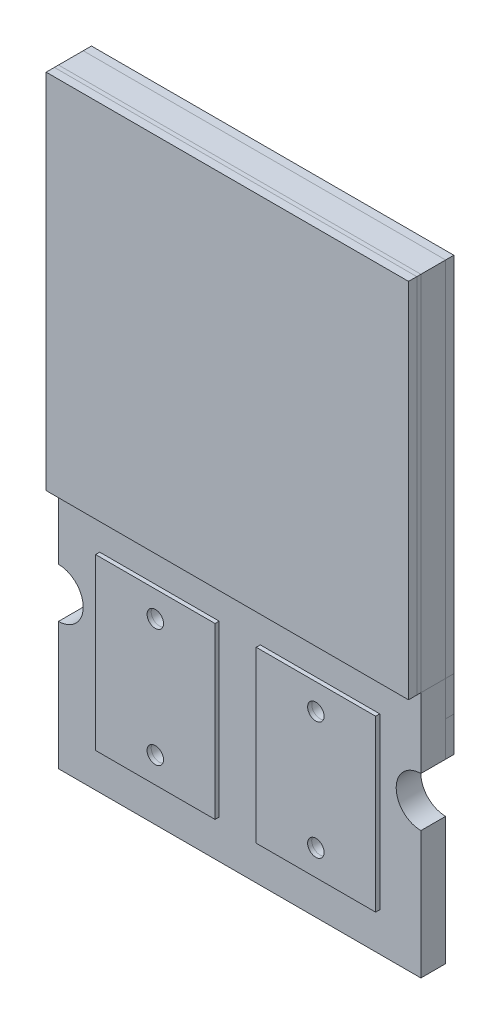
from build123d import *

# Parameters (mm, degrees)
BOSS_EXTRUDE1_DEPTH   = 0.3
BOSS_EXTRUDE2_DEPTH   = 0.05
SKETCH2_W             = 1.449629897
SKETCH2_H             = 1.2
BOSS_EXTRUDE2_2_DEPTH = 0.05
SKETCH2_W_2           = 1.45
SKETCH2_H_2           = 1.199587339
BOSS_EXTRUDE2_3_DEPTH = 0.05
BOSS_EXTRUDE3_DEPTH   = 0.05
SKETCH4_W             = 1.45037802
SKETCH4_H             = 2.060210665
BOSS_EXTRUDE4_DEPTH   = 0.05
SKETCH4_W_2           = 1.449629897
BOSS_EXTRUDE4_2_DEPTH = 0.05
SKETCH4_W_3           = 4.4
SKETCH4_H_2           = 4.4
BOSS_EXTRUDE4_3_DEPTH = 0.05
SKETCH6_W             = 4.399859889
SKETCH6_H             = 4.4
BOSS_EXTRUDE5_DEPTH   = 0.1
SKETCH7_R             = 0.1
CUT_EXTRUDE1_DEPTH    = 0.4


with BuildPart() as part:
    # Model → Boss-Extrude1 (new body)
    with BuildSketch(Plane.XY):
        Polygon((0.000140111, 4.4), (0, 0), (4.400140111, 0), (4.400140111, 4.4), align=None)
        with BuildLine():
            ThreePointArc((4.4, -0.85), (4.1, -1.15), (4.4, -1.45))
            Line((4.4, -1.45), (4.4, -3))
            Line((4.4, -3), (0, -3))
            Line((0, -3), (0, -1.45))
            ThreePointArc((0, -1.45), (0.3, -1.15), (0, -0.85))
            Line((0, -0.85), (0, 0))
            Line((0, 0), (4.400140111, 0))
            Line((4.400140111, 0), (4.4, -0.85))
        make_face()
    extrude(amount=BOSS_EXTRUDE1_DEPTH)


with BuildPart() as body_2:
    # Sketch2 → Boss-Extrude2 (new body)
    with BuildSketch(Plane(origin=(0, 0, 0), x_dir=(-1, 0, 0), z_dir=(0, 0, -1))):
        with BuildLine():
            Line((-4.100667409, -1.13), (-0.299472702, -1.13))
            ThreePointArc((-0.299472702, -1.13), (-0.205079126, -0.930910977), (-0.000140111, -0.85))
            Line((-0.000140111, -0.85), (0, 0))
            Line((0, 0), (-0.000140111, 4.4))
            Line((-0.000140111, 4.4), (-4.4, 4.4))
            Line((-4.4, 4.4), (-4.4, 0))
            Line((-4.4, 0), (-4.400070055, -0.425))
            Line((-4.400070055, -0.425), (-4.4, -0.85))
            ThreePointArc((-4.4, -0.85), (-4.195060985, -0.930910977), (-4.100667409, -1.13))
        make_face()
    extrude(amount=BOSS_EXTRUDE2_DEPTH)

    # Sketch3 → Boss-Extrude3 (add)
    with BuildSketch(Plane(origin=(0, 0, -0.05), x_dir=(-1, 0, 0), z_dir=(0, 0, -1))):
        with BuildLine():
            Line((-0.000140111, -0.850000016), (0, 0))
            Line((0, 0), (-0.000140111, 4.4))
            Line((-0.000140111, 4.4), (-4.4, 4.4))
            Line((-4.4, 4.4), (-4.4, 0))
            Line((-4.4, 0), (-4.400070055, -0.425))
            Line((-4.400070055, -0.425), (-4.4, -0.85))
            ThreePointArc((-4.4, -0.85), (-4.195060985, -0.930910977), (-4.100667409, -1.13))
            Line((-4.100667409, -1.13), (-0.299472685, -1.130000001))
            ThreePointArc((-0.299472685, -1.130000001), (-0.205079115, -0.930910989), (-0.000140111, -0.850000016))
        make_face()
    extrude(amount=BOSS_EXTRUDE3_DEPTH)


with BuildPart() as body_3:
    # Sketch2 → Boss-Extrude2 2 (new body)
    with BuildSketch(Plane(origin=(0, 0, 0), x_dir=(-1, 0, 0), z_dir=(0, 0, -1))):
        with Locations((-3.174585387, -2.4)):
            Rectangle(SKETCH2_W, SKETCH2_H)
    extrude(amount=BOSS_EXTRUDE2_2_DEPTH)


with BuildPart() as body_4:
    # Sketch2 → Boss-Extrude2 3 (new body)
    with BuildSketch(Plane(origin=(0, 0, 0), x_dir=(-1, 0, 0), z_dir=(0, 0, -1))):
        with Locations((-1.224770438, -2.400206331)):
            Rectangle(SKETCH2_W_2, SKETCH2_H_2)
    extrude(amount=BOSS_EXTRUDE2_3_DEPTH)


with BuildPart() as body_5:
    # Sketch4 → Boss-Extrude4 (new body)
    with BuildSketch(Plane.XY.offset(0.3)):
        with Locations((3.175418572, -1.502294159)):
            Rectangle(SKETCH4_W, SKETCH4_H)
    extrude(amount=BOSS_EXTRUDE4_DEPTH)


with BuildPart() as body_6:
    # Sketch4 → Boss-Extrude4 2 (new body)
    with BuildSketch(Plane.XY.offset(0.3)):
        with Locations((1.225414614, -1.502294159)):
            Rectangle(SKETCH4_W_2, SKETCH4_H)
    extrude(amount=BOSS_EXTRUDE4_2_DEPTH)


with BuildPart() as body_7:
    # Sketch4 → Boss-Extrude4 3 (new body)
    with BuildSketch(Plane.XY.offset(0.3)):
        with Locations((2.2, 2.2)):
            Rectangle(SKETCH4_W_3, SKETCH4_H_2)
    extrude(amount=BOSS_EXTRUDE4_3_DEPTH)


with BuildPart() as body_8:
    # Sketch6 → Boss-Extrude5 (new body)
    with BuildSketch(Plane.XY.offset(0.35)):
        with Locations((2.200070056, 2.2)):
            Rectangle(SKETCH6_W, SKETCH6_H)
    extrude(amount=BOSS_EXTRUDE5_DEPTH)


with BuildPart() as cut_extrude1_tool:
    # Sketch7 → Cut-Extrude1 (new body)
    with BuildSketch(Plane.XY.offset(0.35)):
        with Locations((1.225414614, -0.786125011)):
            Circle(SKETCH7_R)
        with Locations((1.225414614, -2.218463306)):
            Circle(SKETCH7_R)
        with Locations((3.174621886, -2.218508824)):
            Circle(SKETCH7_R)
        with Locations((3.174688781, -0.78617053)):
            Circle(SKETCH7_R)
    extrude(amount=-CUT_EXTRUDE1_DEPTH)


with BuildPart() as part_1:
    add(part.part)

    # Cut-Extrude1: cut by cut_extrude1_tool
    add(cut_extrude1_tool.part, mode=Mode.SUBTRACT)


with BuildPart() as body_2_1:
    add(body_2.part)

    # Cut-Extrude1: cut by cut_extrude1_tool
    add(cut_extrude1_tool.part, mode=Mode.SUBTRACT)


with BuildPart() as body_3_1:
    add(body_3.part)

    # Cut-Extrude1: cut by cut_extrude1_tool
    add(cut_extrude1_tool.part, mode=Mode.SUBTRACT)


with BuildPart() as body_4_1:
    add(body_4.part)

    # Cut-Extrude1: cut by cut_extrude1_tool
    add(cut_extrude1_tool.part, mode=Mode.SUBTRACT)


with BuildPart() as body_5_1:
    add(body_5.part)

    # Cut-Extrude1: cut by cut_extrude1_tool
    add(cut_extrude1_tool.part, mode=Mode.SUBTRACT)


with BuildPart() as body_6_1:
    add(body_6.part)

    # Cut-Extrude1: cut by cut_extrude1_tool
    add(cut_extrude1_tool.part, mode=Mode.SUBTRACT)


solid = Compound([body_7.part, body_8.part, part_1.part, body_2_1.part, body_3_1.part, body_4_1.part, body_5_1.part, body_6_1.part])
